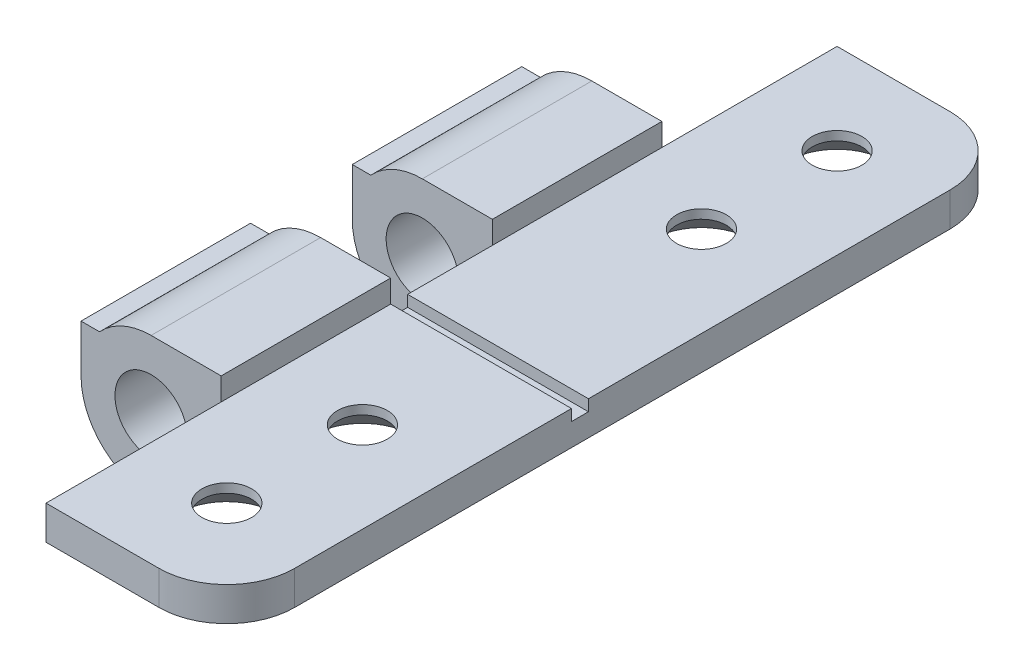
from build123d import *

# Parameters (mm, degrees)
SKETCH2_R           = 1.6
BOSS_EXTRUDE1_DEPTH = 7.5
SKETCH4_W           = 8
SKETCH4_H           = 1.5
BOSS_EXTRUDE3_DEPTH = 4.5
SKETCH5_R           = 1.6
BOSS_EXTRUDE4_DEPTH = 7.5
SKETCH6_W           = 8
SKETCH6_H           = 1.5
BOSS_EXTRUDE5_DEPTH = 7.75
SKETCH7_W           = 8
SKETCH7_H           = 1.5
BOSS_EXTRUDE6_DEPTH = 7.75
SKETCH8_W           = 0.75
SKETCH8_H           = 0.5
CUT_EXTRUDE1_DEPTH  = 9
SKETCH9_R           = 1.1
CUT_EXTRUDE2_DEPTH  = 3.5
CHAMFER1_SIZE       = 1.1
FILLET1_R           = 3


with BuildPart() as part:
    # Sketch2 → Boss-Extrude1 (new body)
    with BuildSketch(Plane.XY):
        with BuildLine():
            Line((3.1, 2.1), (11.1, 2.1))
            Line((11.1, 2.1), (11.1, 0.6))
            Line((11.1, 0.6), (3.1, 0.6))
            Line((3.1, 0.6), (3.1, 0))
            ThreePointArc((3.1, 0), (0, -3.1), (-3.1, 0))
            Line((-3.1, 0), (-3.1, 2.1))
            Line((-3.1, 2.1), (-2.28035085, 2.1))
            ThreePointArc((-2.28035085, 2.1), (-1.24498996, 2.839013913), (0, 3.1))
            Line((0, 3.1), (3.1, 3.1))
            Line((3.1, 3.1), (3.1, 2.1))
        make_face()
        Circle(SKETCH2_R, mode=Mode.SUBTRACT)
    extrude(amount=BOSS_EXTRUDE1_DEPTH)

    # Sketch4 → Boss-Extrude3 (add)
    with BuildSketch(Plane.XY.offset(7.5)):
        with Locations((7.1, 1.35)):
            Rectangle(SKETCH4_W, SKETCH4_H)
    extrude(amount=BOSS_EXTRUDE3_DEPTH)

    # Sketch5 → Boss-Extrude4 (add)
    with BuildSketch(Plane.XY.offset(12)):
        with BuildLine():
            Line((11.1, 0.6), (11.1, 2.1))
            Line((11.1, 2.1), (3.1, 2.1))
            Line((3.1, 2.1), (3.1, 3.1))
            Line((3.1, 3.1), (0, 3.1))
            ThreePointArc((0, 3.1), (-1.24498996, 2.839013913), (-2.28035085, 2.1))
            Line((-2.28035085, 2.1), (-3.1, 2.1))
            Line((-3.1, 2.1), (-3.1, 0))
            ThreePointArc((-3.1, 0), (0, -3.1), (3.1, 0))
            Line((3.1, 0), (3.1, 0.6))
            Line((3.1, 0.6), (11.1, 0.6))
        make_face()
        Circle(SKETCH5_R, mode=Mode.SUBTRACT)
    extrude(amount=BOSS_EXTRUDE4_DEPTH)

    # Sketch6 → Boss-Extrude5 (add)
    with BuildSketch(Plane.XY.offset(19.5)):
        with Locations((7.1, 1.35)):
            Rectangle(SKETCH6_W, SKETCH6_H)
    extrude(amount=BOSS_EXTRUDE5_DEPTH)

    # Sketch7 → Boss-Extrude6 (add)
    with BuildSketch(Plane(origin=(0, 0, 0), x_dir=(-1, 0, 0), z_dir=(0, 0, -1))):
        with Locations((-7.1, 1.35)):
            Rectangle(SKETCH7_W, SKETCH7_H)
    extrude(amount=BOSS_EXTRUDE6_DEPTH)

    # Sketch8 → Cut-Extrude1 (cut, through all)
    with BuildSketch(Plane.ZY.offset(-3.1)):
        with Locations((11.625, 1.85)):
            Rectangle(SKETCH8_W, SKETCH8_H)
    extrude(amount=-CUT_EXTRUDE1_DEPTH, mode=Mode.SUBTRACT)

    # Sketch9 → Cut-Extrude2 (cut, through all)
    with BuildSketch(Plane.XZ.offset(-0.6)):
        with Locations((7.1, 23.25)):
            Circle(SKETCH9_R)
        with Locations((7.1, 17.25)):
            Circle(SKETCH9_R)
        with Locations((7.1, 2.25)):
            Circle(SKETCH9_R)
        with Locations((7.1, -3.75)):
            Circle(SKETCH9_R)
    extrude(amount=-CUT_EXTRUDE2_DEPTH, mode=Mode.SUBTRACT)

    # Chamfer1
    chamfer1_edges = [part.edges().sort_by_distance(p)[0] for p in [
        (6, 0.6, 23.25),
        (6, 0.6, 17.25),
        (6, 0.6, 2.25),
        (6, 0.6, -3.75),
    ]]
    chamfer(chamfer1_edges, length=CHAMFER1_SIZE)

    # Fillet1
    fillet1_edges = [part.edges().sort_by_distance(p)[0] for p in [
        (11.1, 1.35, 27.25),
        (11.1, 1.35, -7.75),
    ]]
    fillet(fillet1_edges, radius=FILLET1_R)


solid = part.part
